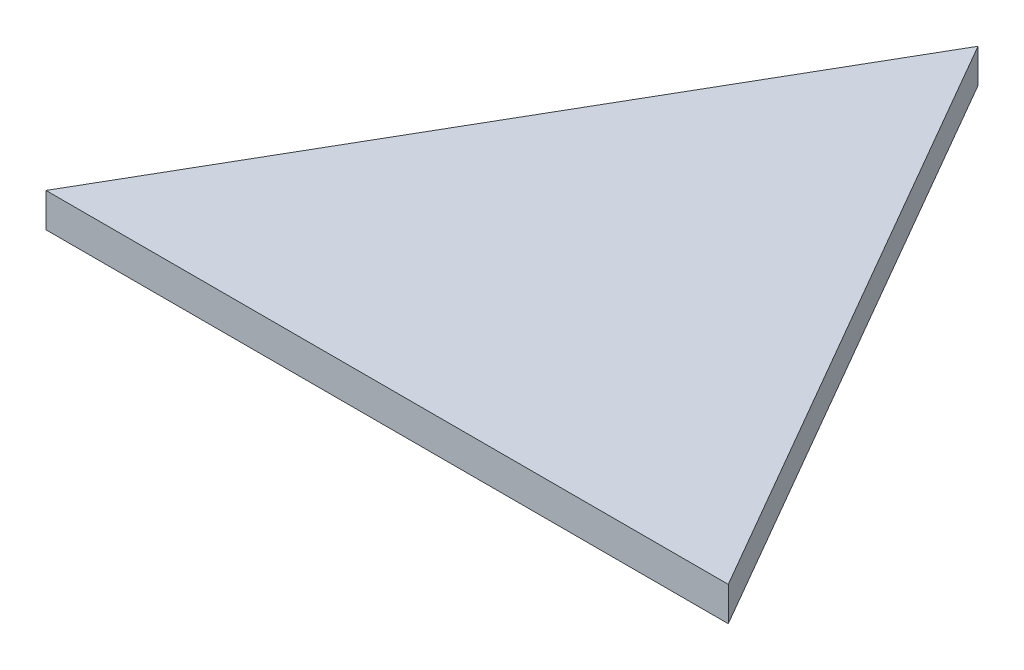
from build123d import *

# Parameters (mm, degrees)
BOSS_EXTRUDE1_DEPTH = 1.27


with BuildPart() as part:
    # Sketch2 → Boss-Extrude1 (new body)
    with BuildSketch(Plane(origin=(0, 0, 0), x_dir=(1, 0, 0), z_dir=(0, 1, 0))):
        Polygon((0, 0), (25.4, 0), (12.7, 21.997045256), align=None)
    extrude(amount=BOSS_EXTRUDE1_DEPTH)


solid = part.part
